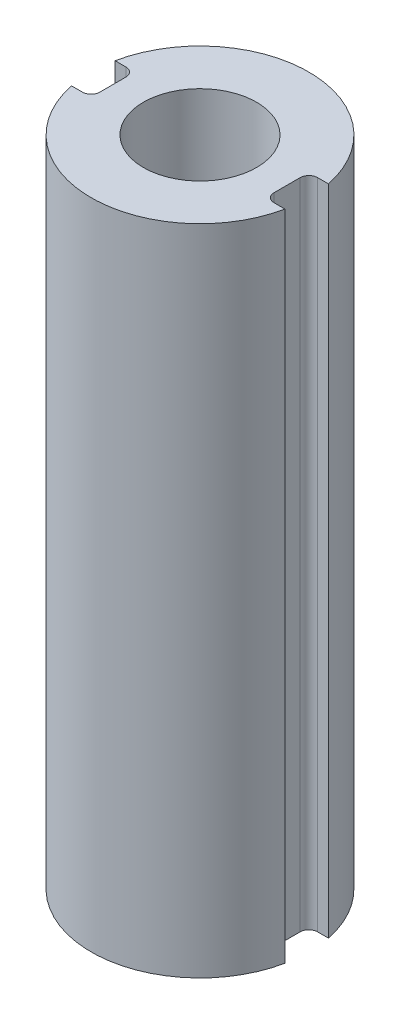
from build123d import *

# Parameters (mm, degrees)
BOSS_EXTRUDE1_DEPTH = 19.05
SKETCH2_R           = 1.651
CUT_EXTRUDE1_DEPTH  = 12.7
FILLET1_R           = 0.254


with BuildPart() as part:
    # Sketch1 → Boss-Extrude1 (new body)
    with BuildSketch(Plane(origin=(0, 0, 0), x_dir=(1, 0, 0), z_dir=(0, 1, 0))):
        with BuildLine():
            Line((2.54, -0.635), (3.110851973, -0.635))
            ThreePointArc((3.110851973, -0.635), (0, -3.175), (-3.110851973, -0.635))
            Line((-3.110851973, -0.635), (-2.54, -0.635))
            Line((-2.54, -0.635), (-2.54, 0.635))
            Line((-2.54, 0.635), (-3.110851973, 0.635))
            ThreePointArc((-3.110851973, 0.635), (0, 3.175), (3.110851973, 0.635))
            Line((3.110851973, 0.635), (2.54, 0.635))
            Line((2.54, 0.635), (2.54, -0.635))
        make_face()
    extrude(amount=BOSS_EXTRUDE1_DEPTH)

    # Sketch2 → Cut-Extrude1 (cut)
    with BuildSketch(Plane(origin=(0, 19.05, 0), x_dir=(1, 0, 0), z_dir=(0, 1, 0))):
        Circle(SKETCH2_R)
    extrude(amount=-CUT_EXTRUDE1_DEPTH, mode=Mode.SUBTRACT)

    # Fillet1
    fillet1_edges = [part.edges().sort_by_distance(p)[0] for p in [
        (2.54, 9.525, 0.635),
        (-2.54, 9.525, 0.635),
        (-2.54, 9.525, -0.635),
        (2.54, 9.525, -0.635),
    ]]
    fillet(fillet1_edges, radius=FILLET1_R)


solid = part.part
